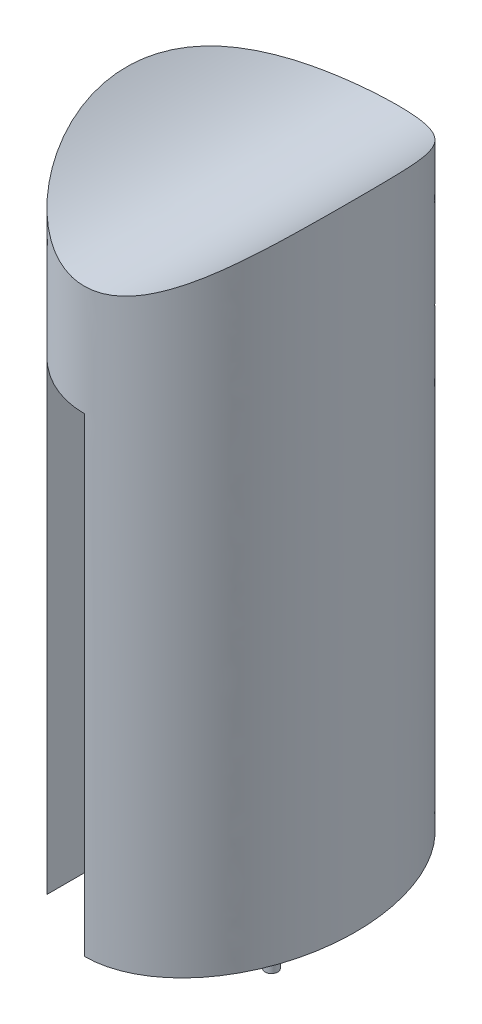
from build123d import *

# Parameters (mm, degrees)
SKETCH2_RX              = 130
SKETCH2_RY              = 95
SKETCH2_RX_2            = 100
SKETCH2_RY_2            = 65
BOSS_EXTRUDE2_DEPTH     = 240
CUT_EXTRUDE1_DEPTH      = 390
BOSS_EXTRUDE3_DEPTH     = 130
CUT_EXTRUDE4_DEPTH      = 551.689468553
CUT_EXTRUDE4_DEPTH_BACK = 551.689468553
SKETCH6_W               = 486.837631078
SKETCH6_H               = 577.83259316
BOSS_EXTRUDE4_DEPTH     = 521


with BuildPart() as part:
    # Sketch2 → Boss-Extrude2 (new, symmetric)
    with BuildSketch(Plane(origin=(0, 0, 0), x_dir=(1, 0, 0), z_dir=(0, 1, 0))):
        with Locations(Location((0, 0), (0, 0, 90))):
            Ellipse(SKETCH2_RX, SKETCH2_RY)
        with Locations(Location((0, 0), (0, 0, 90))):
            Ellipse(SKETCH2_RX_2, SKETCH2_RY_2, mode=Mode.SUBTRACT)
    extrude(amount=BOSS_EXTRUDE2_DEPTH, both=True)

    # Sketch4 → Cut-Extrude1 (cut)
    with BuildSketch(Plane.XZ.offset(240)):
        with BuildLine():
            Line((0, 100), (0, 130))
            add(Edge.make_bspline(
                [(0, 130), (-33.796884421, 130), (-60, 100.790504323)],
                knots=[3.141592654, 3.141592654, 3.141592654, 3.825180713, 3.825180713, 3.825180713], degree=2, weights=[1, 0.942154863, 1]))
            Line((-60, 100.790504323), (-60, 38.461538462))
            add(Edge.make_bspline(
                [(0, 100), (-43.333333333, 100), (-60, 38.461538462)],
                knots=[3.141592654, 3.141592654, 3.141592654, 4.317597861, 4.317597861, 4.317597861], degree=2, weights=[1, 0.832050294, 1]))
        make_face()
    extrude(amount=-CUT_EXTRUDE1_DEPTH, mode=Mode.SUBTRACT)

    # Sketch5 → Boss-Extrude3 (add, symmetric)
    with BuildSketch(Plane.XY):
        with BuildLine():
            Line((95, 286.625), (95, 240))
            Line((95, 240), (-95, 240))
            Line((-95, 240), (-95, 286.625))
            add(Edge.make_bspline(
                [(-95, 286.625), (0, 196.375), (95, 286.625)],
                knots=[0.068509006, 0.068509006, 0.068509006, 0.931490994, 0.931490994, 0.931490994], degree=2))
        make_face()
    extrude(amount=BOSS_EXTRUDE3_DEPTH, both=True)

    # Sketch6 → Cut-Extrude4 (cut, two sides: drawn at the far end of the back side and taken through both)
    with BuildSketch(Plane.XZ.offset(240).offset(-CUT_EXTRUDE4_DEPTH_BACK)):
        with Locations((-17.689854082, 33.68650554)):
            Rectangle(SKETCH6_W, SKETCH6_H)
        with BuildLine():
            add(Edge.make_bspline(
                [(-95, 0), (-95, -130), (0, -130)],
                knots=[4.71238898, 4.71238898, 4.71238898, 6.283185307, 6.283185307, 6.283185307], degree=2, weights=[1, 0.707106781, 1]))
            add(Edge.make_bspline(
                [(0, -130), (95, -130), (95, 0)],
                knots=[0, 0, 0, 1.570796327, 1.570796327, 1.570796327], degree=2, weights=[1, 0.707106781, 1]))
            add(Edge.make_bspline(
                [(95, 0), (95, 130), (0, 130)],
                knots=[1.570796327, 1.570796327, 1.570796327, 3.141592654, 3.141592654, 3.141592654], degree=2, weights=[1, 0.707106781, 1]))
            add(Edge.make_bspline(
                [(0, 130), (-95, 130), (-95, 0)],
                knots=[3.141592654, 3.141592654, 3.141592654, 4.71238898, 4.71238898, 4.71238898], degree=2, weights=[1, 0.707106781, 1]))
        make_face(mode=Mode.SUBTRACT)
    extrude(amount=CUT_EXTRUDE4_DEPTH + CUT_EXTRUDE4_DEPTH_BACK, mode=Mode.SUBTRACT)

    # Sketch7 → Boss-Extrude4 (add)
    with BuildSketch(Plane.XZ.offset(-240)):
        with BuildLine():
            Line((5.25, 14.75), (5.25, -14.75))
            ThreePointArc((5.25, -14.75), (1.537689399, -23.712310601), (10.5, -20))
            Line((10.5, -20), (40, -20))
            ThreePointArc((40, -20), (48.962310601, -23.712310601), (45.25, -14.75))
            Line((45.25, -14.75), (45.25, 14.75))
            ThreePointArc((45.25, 14.75), (48.962310601, 23.712310601), (40, 20))
            Line((40, 20), (10.5, 20))
            ThreePointArc((10.5, 20), (1.537689399, 23.712310601), (5.25, 14.75))
        make_face()
    extrude(amount=BOSS_EXTRUDE4_DEPTH)


solid = part.part
